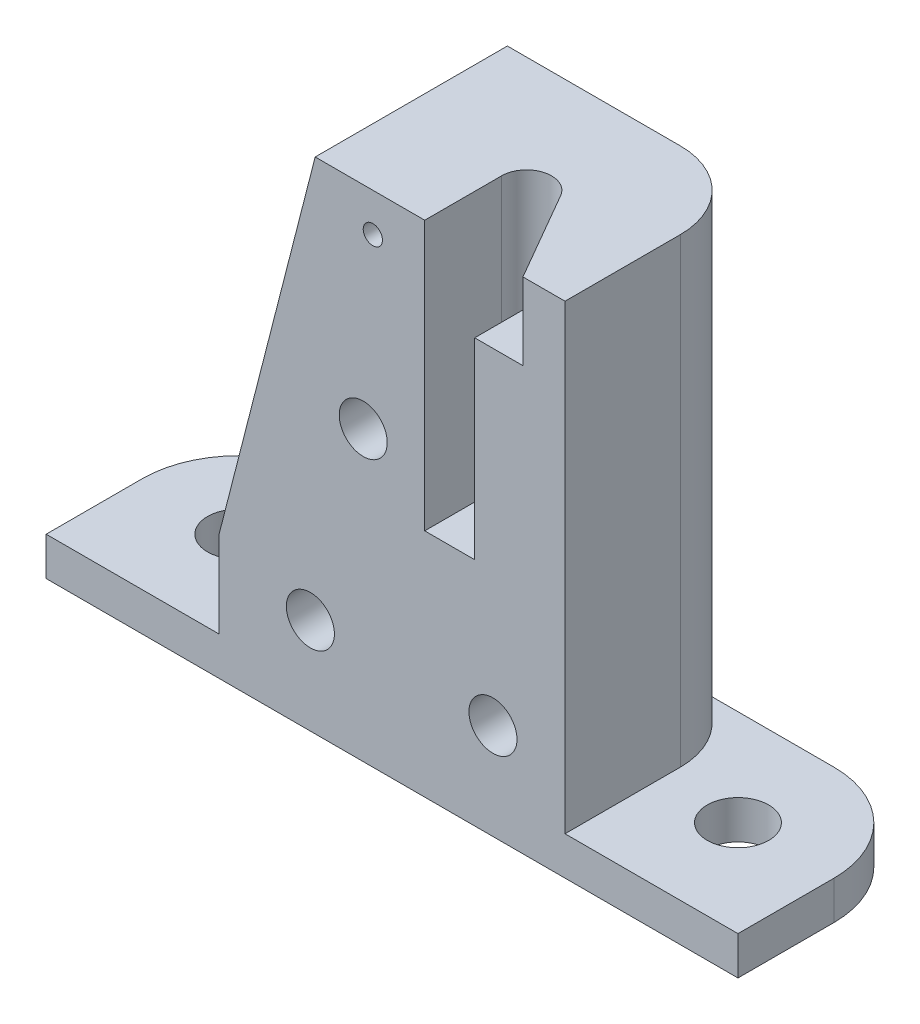
from build123d import *

# Parameters (mm, degrees)
SKETCH1_R           = 1.6
BOSS_EXTRUDE1_DEPTH = 2
BOSS_EXTRUDE2_DEPTH = 26
CUT_EXTRUDE1_REACH  = 28
SKETCH3_R           = 1.2
CUT_EXTRUDE2_DEPTH  = 4
CUT_EXTRUDE3_DEPTH  = 14
CUT_EXTRUDE4_REACH  = 12
SKETCH6_R           = 0.5
SKETCH6_R_2         = 1.25


with BuildPart() as part:
    # Sketch1 → Boss-Extrude1 (new body)
    with BuildSketch(Plane(origin=(0, 0, 0), x_dir=(1, 0, 0), z_dir=(0, 1, 0))):
        with BuildLine():
            Line((0, 0), (36, 0))
            Line((36, 0), (36, 5))
            ThreePointArc((36, 5), (34.535533906, 8.535533906), (31, 10))
            Line((31, 10), (27, 10))
            Line((27, 10), (9, 10))
            Line((9, 10), (5, 10))
            ThreePointArc((5, 10), (1.464466094, 8.535533906), (0, 5))
            Line((0, 5), (0, 0))
        make_face()
        with Locations((5, 5)):
            Circle(SKETCH1_R, mode=Mode.SUBTRACT)
        with Locations((31, 5)):
            Circle(SKETCH1_R, mode=Mode.SUBTRACT)
    extrude(amount=BOSS_EXTRUDE1_DEPTH)

    # Sketch2 → Boss-Extrude2 (add)
    with BuildSketch(Plane(origin=(0, 0, 0), x_dir=(1, 0, 0), z_dir=(0, 1, 0))):
        with BuildLine():
            Line((27, 0), (27, 6))
            ThreePointArc((27, 6), (25.828427125, 8.828427125), (23, 10))
            Line((23, 10), (13, 10))
            ThreePointArc((13, 10), (10.171572875, 8.828427125), (9, 6))
            Line((9, 6), (9, 0))
            Line((9, 0), (27, 0))
        make_face()
    extrude(amount=BOSS_EXTRUDE2_DEPTH)

    # Sketch3 → Cut-Extrude1 (cut, up to next)
    with BuildSketch(Plane(origin=(0, 26, 0), x_dir=(1, 0, 0), z_dir=(0, 1, 0)), mode=Mode.PRIVATE) as cut_extrude1_sk1:
        with Locations((21, 4)):
            Circle(SKETCH3_R)
    cut_extrude1_tool1 = extrude(cut_extrude1_sk1.sketch, amount=-CUT_EXTRUDE1_REACH, mode=Mode.PRIVATE) & part.part
    add(cut_extrude1_tool1.solids().sort_by_distance((21, 26, -4))[0], mode=Mode.SUBTRACT)

    # Sketch4 → Cut-Extrude2 (cut)
    with BuildSketch(Plane(origin=(0, 26, 0), x_dir=(1, 0, 0), z_dir=(0, 1, 0))):
        with BuildLine():
            Line((22.125833025, 4.65), (24.810511777, 0))
            Line((24.810511777, 0), (19.7, 0))
            Line((19.7, 0), (19.7, 4))
            ThreePointArc((19.7, 4), (20.663535241, 5.255703574), (22.125833025, 4.65))
        make_face()
    extrude(amount=-CUT_EXTRUDE2_DEPTH, mode=Mode.SUBTRACT)

    # Sketch5 → Cut-Extrude3 (cut)
    with BuildSketch(Plane(origin=(0, 26, 0), x_dir=(1, 0, 0), z_dir=(0, 1, 0))):
        with BuildLine():
            Line((19.7, 4), (19.7, 0))
            Line((19.7, 0), (22.3, 0))
            Line((22.3, 0), (22.3, 4))
            ThreePointArc((22.3, 4), (21, 5.3), (19.7, 4))
        make_face()
    extrude(amount=-CUT_EXTRUDE3_DEPTH, mode=Mode.SUBTRACT)

    # Sketch6 → Cut-Extrude4 (cut, up to next)
    with BuildSketch(Plane.XY, mode=Mode.PRIVATE) as cut_extrude4_sk1:
        with Locations((17, 24)):
            Circle(SKETCH6_R)
    cut_extrude4_tool1 = extrude(cut_extrude4_sk1.sketch, amount=-CUT_EXTRUDE4_REACH, mode=Mode.PRIVATE) & part.part
    add(cut_extrude4_tool1.solids().sort_by_distance((17, 24, 0))[0], mode=Mode.SUBTRACT)
    # Sketch6 → Cut-Extrude4 (cut, up to next)
    with BuildSketch(Plane.XY, mode=Mode.PRIVATE) as cut_extrude4_sk2:
        with Locations((16.5, 15)):
            Circle(SKETCH6_R_2)
    cut_extrude4_tool2 = extrude(cut_extrude4_sk2.sketch, amount=-CUT_EXTRUDE4_REACH, mode=Mode.PRIVATE) & part.part
    add(cut_extrude4_tool2.solids().sort_by_distance((16.5, 15, 0))[0], mode=Mode.SUBTRACT)
    # Sketch6 → Cut-Extrude4 (cut, up to next)
    with BuildSketch(Plane.XY, mode=Mode.PRIVATE) as cut_extrude4_sk3:
        with Locations((13.75, 5)):
            Circle(SKETCH6_R_2)
    cut_extrude4_tool3 = extrude(cut_extrude4_sk3.sketch, amount=-CUT_EXTRUDE4_REACH, mode=Mode.PRIVATE) & part.part
    add(cut_extrude4_tool3.solids().sort_by_distance((13.75, 5, 0))[0], mode=Mode.SUBTRACT)
    # Sketch6 → Cut-Extrude4 (cut, up to next)
    with BuildSketch(Plane.XY, mode=Mode.PRIVATE) as cut_extrude4_sk4:
        with Locations((23.25, 5)):
            Circle(SKETCH6_R_2)
    cut_extrude4_tool4 = extrude(cut_extrude4_sk4.sketch, amount=-CUT_EXTRUDE4_REACH, mode=Mode.PRIVATE) & part.part
    add(cut_extrude4_tool4.solids().sort_by_distance((23.25, 5, 0))[0], mode=Mode.SUBTRACT)
    # Sketch6 → Cut-Extrude4 (cut, up to next)
    with BuildSketch(Plane.XY, mode=Mode.PRIVATE) as cut_extrude4_sk5:
        Polygon((9, 6.5), (14, 26), (9, 26), align=None)
    cut_extrude4_tool5 = extrude(cut_extrude4_sk5.sketch, amount=-CUT_EXTRUDE4_REACH, mode=Mode.PRIVATE) & part.part
    add(cut_extrude4_tool5.solids().sort_by_distance((10.666667, 19.5, 0))[0], mode=Mode.SUBTRACT)


solid = part.part
